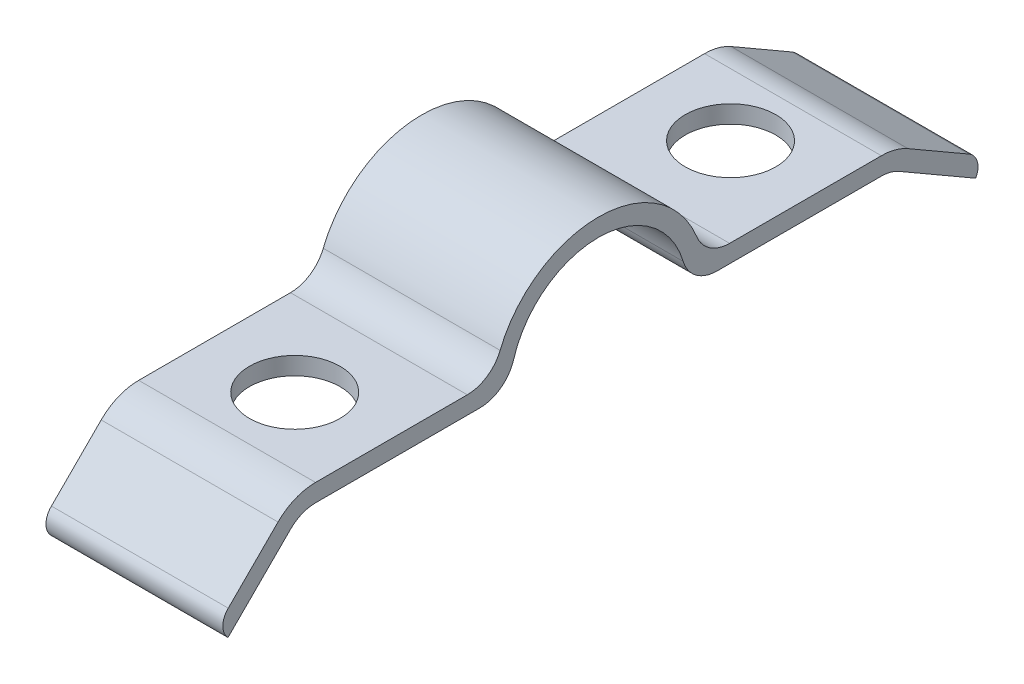
from build123d import *

# Parameters (mm, degrees)
BOSS_EXTRUDE1_DEPTH            = 3.175
CUT_EXTRUDE1_REACH             = 5.252
SKETCH2_R                      = 1.6256
CUT_EXTRUDE1_DIRECTION_2_DEPTH = 4.175


with BuildPart() as part:
    # Sketch1 → Boss-Extrude1 (new body, symmetric)
    with BuildSketch(Plane(origin=(0, 0, 0), x_dir=(0, 0, -1), z_dir=(1, 0, 0))):
        with BuildLine():
            Line((-10.16, 0), (-4.259709497, 0))
            ThreePointArc((-4.259709497, 0), (-3.50073933, 0.251734668), (-3.042649641, 0.907142857))
            ThreePointArc((-3.042649641, 0.907142857), (0, 3.175), (3.042649641, 0.907142857))
            ThreePointArc((3.042649641, 0.907142857), (3.50073933, 0.251734668), (4.259709497, 0))
            Line((4.259709497, 0), (10.16, 0))
            ThreePointArc((10.16, 0), (10.488700187, -0.043274201), (10.795, -0.170147737))
            Line((10.795, -0.170147737), (12.994704526, -1.440147737))
            Line((12.994704526, -1.440147737), (13.544630657, -1.757647737))
            ThreePointArc((13.544630657, -1.757647737), (13.608067425, -1.275797644), (13.312204526, -0.890221606))
            Line((13.312204526, -0.890221606), (11.1125, 0.379778394))
            ThreePointArc((11.1125, 0.379778394), (10.653050281, 0.570088699), (10.16, 0.635))
            Line((10.16, 0.635), (4.709286039, 0.635))
            ThreePointArc((4.709286039, 0.635), (3.999334456, 0.851971629), (3.531964529, 1.42875))
            ThreePointArc((3.531964529, 1.42875), (0, 3.81), (-3.531964529, 1.42875))
            ThreePointArc((-3.531964529, 1.42875), (-3.999334456, 0.851971629), (-4.709286039, 0.635))
            Line((-4.709286039, 0.635), (-10.16, 0.635))
            ThreePointArc((-10.16, 0.635), (-10.889011939, 0.489990509), (-11.507038418, 0.077038418))
            Line((-11.507038418, 0.077038418), (-13.292936294, -1.708859457))
            ThreePointArc((-13.292936294, -1.708859457), (-13.48919858, -2.160845652), (-13.303204425, -2.6171532))
            Line((-13.303204425, -2.6171532), (-12.854076836, -2.168025612))
            Line((-12.854076836, -2.168025612), (-11.058025612, -0.371974388))
            ThreePointArc((-11.058025612, -0.371974388), (-10.646007959, -0.096672994), (-10.16, 0))
        make_face()
    extrude(amount=BOSS_EXTRUDE1_DEPTH, both=True)

    # Sketch2 → Cut-Extrude1 (cut, up to next)
    with BuildSketch(Plane(origin=(0, 0.635, 0), x_dir=(1, 0, 0), z_dir=(0, 1, 0)), mode=Mode.PRIVATE) as cut_extrude1_sk1:
        with Locations((0, -7.73176)):
            Circle(SKETCH2_R)
    cut_extrude1_tool1 = extrude(cut_extrude1_sk1.sketch, amount=-CUT_EXTRUDE1_REACH, mode=Mode.PRIVATE) & part.part
    add(cut_extrude1_tool1.solids().sort_by_distance((0, 0.635, 7.73176))[0], mode=Mode.SUBTRACT)
    # Sketch2 → Cut-Extrude1 (cut, up to next)
    with BuildSketch(Plane(origin=(0, 0.635, 0), x_dir=(1, 0, 0), z_dir=(0, 1, 0)), mode=Mode.PRIVATE) as cut_extrude1_sk2:
        with Locations((0, 7.91718)):
            Circle(SKETCH2_R)
    cut_extrude1_tool2 = extrude(cut_extrude1_sk2.sketch, amount=-CUT_EXTRUDE1_REACH, mode=Mode.PRIVATE) & part.part
    add(cut_extrude1_tool2.solids().sort_by_distance((0, 0.635, -7.91718))[0], mode=Mode.SUBTRACT)

    # Sketch2 → Cut-Extrude1 direction 2 (cut)
    with BuildSketch(Plane(origin=(0, 0.635, 0), x_dir=(1, 0, 0), z_dir=(0, 1, 0))):
        with Locations((0, -7.73176)):
            Circle(SKETCH2_R)
        with Locations((0, 7.91718)):
            Circle(SKETCH2_R)
    extrude(amount=CUT_EXTRUDE1_DIRECTION_2_DEPTH, mode=Mode.SUBTRACT)


solid = part.part
